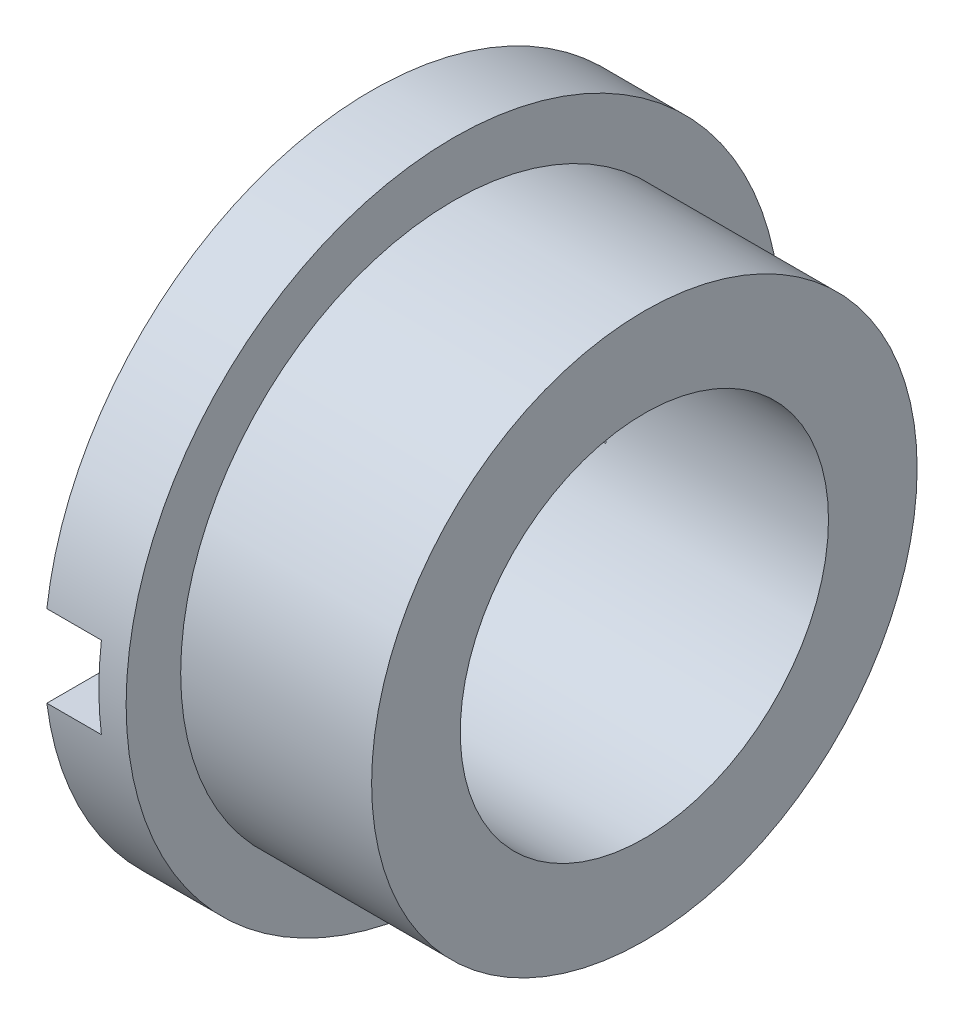
from build123d import *

# Parameters (mm, degrees)
ESQUISSE1_R                  = 5
ESQUISSE1_R_2                = 3.375
EXTRUSION1_DEPTH             = 3.5
EXTRUSION1_DEPTH_BACK        = 1.5
ESQUISSE2_R                  = 6
ESQUISSE2_R_2                = 3.375
EXTRUSION2_DEPTH             = 1.5
ESQUISSE3_W                  = 1
ESQUISSE3_H                  = 1.5
ENL_V_MAT_EXTRU_1_DEPTH      = 7
ENL_V_MAT_EXTRU_1_DEPTH_BACK = 7


with BuildPart() as part:
    # Esquisse1 → Extrusion1 (new body, two sides)
    with BuildSketch(Plane(origin=(0, 0, 0), x_dir=(0, 0, -1), z_dir=(1, 0, 0))) as extrusion1_sk:
        Circle(ESQUISSE1_R)
        Circle(ESQUISSE1_R_2, mode=Mode.SUBTRACT)
    extrude(amount=EXTRUSION1_DEPTH)
    extrude(extrusion1_sk.sketch, amount=-EXTRUSION1_DEPTH_BACK)

    # Esquisse2 → Extrusion2 (add)
    with BuildSketch(Plane(origin=(0, 0, 0), x_dir=(0, 0, -1), z_dir=(1, 0, 0))):
        Circle(ESQUISSE2_R)
        Circle(ESQUISSE2_R_2, mode=Mode.SUBTRACT)
    extrude(amount=-EXTRUSION2_DEPTH)

    # Esquisse3 → Enlèv. mat.-Extru.1 (cut, two sides)
    with BuildSketch(Plane.XY) as enl_v_mat_extru_1_sk:
        with Locations((-1, 0)):
            Rectangle(ESQUISSE3_W, ESQUISSE3_H)
    extrude(amount=ENL_V_MAT_EXTRU_1_DEPTH, mode=Mode.SUBTRACT)
    extrude(enl_v_mat_extru_1_sk.sketch, amount=-ENL_V_MAT_EXTRU_1_DEPTH_BACK, mode=Mode.SUBTRACT)


solid = part.part
